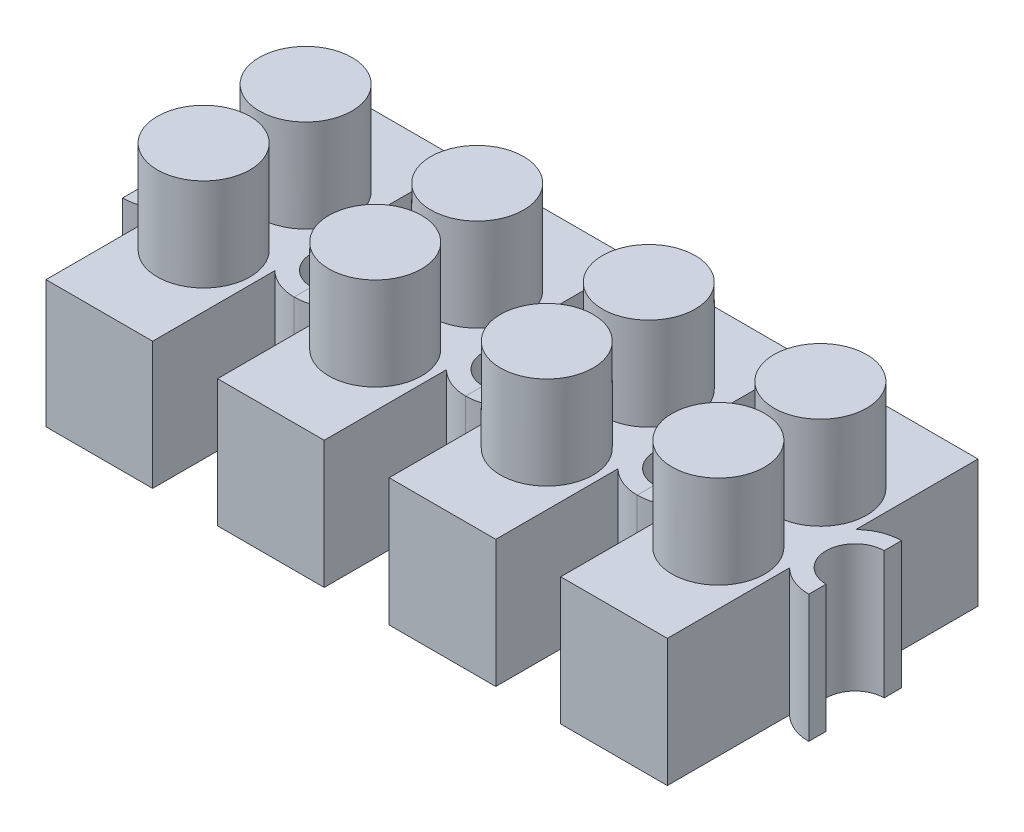
from build123d import *

# Parameters (mm, degrees)
BOSS_EXTRUDE1_DEPTH = 6.985
SKETCH3_W           = 4.572
SKETCH3_H           = 15.494
CUT_EXTRUDE1_DEPTH  = 1.27
SKETCH6_R           = 2.54
BOSS_EXTRUDE3_DEPTH = 5.08
LPATTERN1_COUNT     = 4
LPATTERN1_PITCH     = 9.398


with BuildPart() as part:
    # Sketch2 → Boss-Extrude1 (new body)
    with BuildSketch(Plane(origin=(0, 0, 0), x_dir=(1, 0, 0), z_dir=(0, 1, 0))):
        with BuildLine():
            Line((2.921, 8.509), (-2.921, 8.509))
            Line((-2.921, 8.509), (-2.921, 1.813922821))
            ThreePointArc((-2.921, 1.813922821), (-3.738730237, 2.351485059), (-4.699, 2.54))
            Line((-4.699, 2.54), (-4.699, 1.5875))
            ThreePointArc((-4.699, 1.5875), (-3.1115, 0), (-4.699, -1.5875))
            Line((-4.699, -1.5875), (-4.699, -2.54))
            ThreePointArc((-4.699, -2.54), (-3.738730237, -2.351485059), (-2.921, -1.813922821))
            Line((-2.921, -1.813922821), (-2.921, -8.509))
            Line((-2.921, -8.509), (2.921, -8.509))
            Line((2.921, -8.509), (2.921, -1.813922821))
            ThreePointArc((2.921, -1.813922821), (3.738730237, -2.351485059), (4.699, -2.54))
            Line((4.699, -2.54), (4.699, -1.5875))
            ThreePointArc((4.699, -1.5875), (3.1115, 0), (4.699, 1.5875))
            Line((4.699, 1.5875), (4.699, 2.54))
            ThreePointArc((4.699, 2.54), (3.738730237, 2.351485059), (2.921, 1.813922821))
            Line((2.921, 1.813922821), (2.921, 8.509))
        make_face()
    extrude(amount=BOSS_EXTRUDE1_DEPTH)

    # Sketch3 → Cut-Extrude1 (cut)
    with BuildSketch(Plane.XZ):
        Rectangle(SKETCH3_W, SKETCH3_H)
    extrude(amount=-CUT_EXTRUDE1_DEPTH, mode=Mode.SUBTRACT)

    # Sketch6 → Boss-Extrude3 (add)
    with BuildSketch(Plane(origin=(0, 6.985, 0), x_dir=(1, 0, 0), z_dir=(0, 1, 0))):
        with Locations((0, 2.794)):
            Circle(SKETCH6_R)
        with Locations((0, -2.794)):
            Circle(SKETCH6_R)
    extrude(amount=BOSS_EXTRUDE3_DEPTH)


with BuildPart() as lpattern1_1:
    # LPattern1: pattern copy
    add(part.part.moved(Location(Vector(-1, 0, 0) * (1 * LPATTERN1_PITCH))))


with BuildPart() as lpattern1_2:
    # LPattern1: pattern copy
    add(part.part.moved(Location(Vector(-1, 0, 0) * (2 * LPATTERN1_PITCH))))


with BuildPart() as lpattern1_3:
    # LPattern1: pattern copy
    add(part.part.moved(Location(Vector(-1, 0, 0) * (3 * LPATTERN1_PITCH))))


solid = Compound([part.part, lpattern1_1.part, lpattern1_2.part, lpattern1_3.part])
